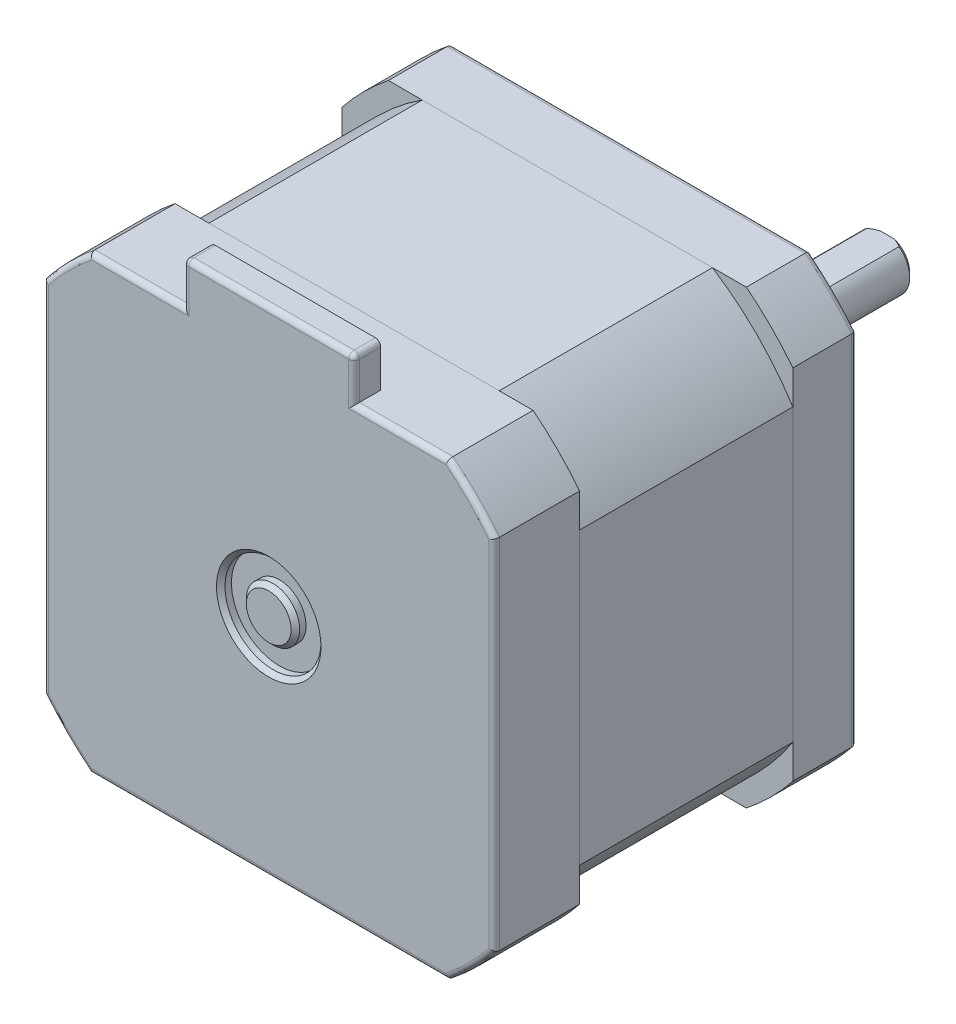
from build123d import *

# Parameters (mm, degrees)
BOSS_EXTRU_1_DEPTH           = 6
BOSS_EXTRU_2_DEPTH           = 20
BOSS_EXTRU_3_DEPTH           = 8
ESQUISSE4_W                  = 16
ESQUISSE4_H                  = 2.5
BOSS_EXTRU_4_DEPTH           = 4
ESQUISSE5_W                  = 2
ESQUISSE5_H                  = 6.5
ESQUISSE5_W_2                = 24
ESQUISSE5_H_2                = 2.5
CONG_1_R                     = 0.5
CONG_2_R                     = 0.5
CHANFREIN1_SIZE              = 0.4
CHANFREIN2_SIZE              = 0.4
ESQUISSE6_W                  = 15
ESQUISSE6_H                  = 0.5
ENL_V_MAT_EXTRU_1_DEPTH      = 22.1500001
ENL_V_MAT_EXTRU_1_DEPTH_BACK = 22.1500001
ESQUISSE7_R                  = 4.5
ESQUISSE7_R_2                = 2.5
ENL_V_MAT_EXTRU_2_DEPTH      = 1
CHANFREIN3_SIZE              = 0.4
TROU_TARAUD_M31_AT_2_COUNT   = 2
TROU_TARAUD_M31_AT_2_PITCH   = 31
TROU_TARAUD_M31_AT_3_COUNT   = 2
TROU_TARAUD_M31_AT_3_PITCH   = 43.840620434
TROU_TARAUD_M31_AT_4_COUNT   = 2
TROU_TARAUD_M31_AT_4_PITCH   = 31


with BuildPart() as part:
    # Esquisse1 → Boss.-Extru.1 (new body)
    with BuildSketch(Plane.XY):
        with BuildLine():
            Line((21.15, 16.783250579), (21.15, -16.783250579))
            ThreePointArc((21.15, -16.783250579), (19.091883092, -19.091883092), (16.783250579, -21.15))
            Line((16.783250579, -21.15), (-16.783250579, -21.15))
            ThreePointArc((-16.783250579, -21.15), (-19.091883092, -19.091883092), (-21.15, -16.783250579))
            Line((-21.15, -16.783250579), (-21.15, 16.783250579))
            ThreePointArc((-21.15, 16.783250579), (-19.091883092, 19.091883092), (-16.783250579, 21.15))
            Line((-16.783250579, 21.15), (16.783250579, 21.15))
            ThreePointArc((16.783250579, 21.15), (19.091883092, 19.091883092), (21.15, 16.783250579))
        make_face()
    extrude(amount=BOSS_EXTRU_1_DEPTH)

    # Congé2
    cong_2_edges = [part.edges().sort_by_distance(p)[0] for p in [
        (0, 21.15, 0),
        (19.091883092, 19.091883092, 0),
        (21.15, 0, 0),
        (19.091883092, -19.091883092, 0),
        (0, -21.15, 0),
        (-19.091883092, -19.091883092, 0),
        (-21.15, 0, 0),
        (-19.091883092, 19.091883092, 0),
    ]]
    fillet(cong_2_edges, radius=CONG_2_R)

    # Esquisse9 → Trou taraudé M31 (revolve, cut)
    with BuildSketch(Plane(origin=(15.5, -15.5, 0), x_dir=(0, 1, 0), z_dir=(1, 0, 0))):
        Polygon((0, 0), (0, 5.751075774), (1.25, 5), (1.25, 0), align=None)
    trou_taraud_m31 = revolve(axis=Axis((15.5, -15.5, -6.35), (0, 0, 1)), mode=Mode.SUBTRACT)

    # Trou taraudé M31 at 2: Trou taraudé M31 ×2
    with Locations(*[(0, i * TROU_TARAUD_M31_AT_2_PITCH, 0) for i in range(1, TROU_TARAUD_M31_AT_2_COUNT)]):
        add(trou_taraud_m31, mode=Mode.SUBTRACT)

    # Trou taraudé M31 at 3: Trou taraudé M31 ×2
    with Locations(*[Vector(-0.707106781, 0.707106781, 0) * (i * TROU_TARAUD_M31_AT_3_PITCH) for i in range(1, TROU_TARAUD_M31_AT_3_COUNT)]):
        add(trou_taraud_m31, mode=Mode.SUBTRACT)

    # Trou taraudé M31 at 4: Trou taraudé M31 ×2
    with Locations(*[(-i * TROU_TARAUD_M31_AT_4_PITCH, 0, 0) for i in range(1, TROU_TARAUD_M31_AT_4_COUNT)]):
        add(trou_taraud_m31, mode=Mode.SUBTRACT)


with BuildPart() as body_2:
    # Esquisse2 → Boss.-Extru.2 (new body)
    with BuildSketch(Plane.XY.offset(6)):
        with BuildLine():
            Line((-13.608820669, 21.15), (13.608820669, 21.15))
            ThreePointArc((13.608820669, 21.15), (17.783735547, 17.783735547), (21.15, 13.608820669))
            Line((21.15, 13.608820669), (21.15, -13.608820669))
            ThreePointArc((21.15, -13.608820669), (17.783735547, -17.783735547), (13.608820669, -21.15))
            Line((13.608820669, -21.15), (-13.608820669, -21.15))
            ThreePointArc((-13.608820669, -21.15), (-17.783735547, -17.783735547), (-21.15, -13.608820669))
            Line((-21.15, -13.608820669), (-21.15, 13.608820669))
            ThreePointArc((-21.15, 13.608820669), (-17.783735547, 17.783735547), (-13.608820669, 21.15))
        make_face()
    extrude(amount=BOSS_EXTRU_2_DEPTH)


with BuildPart() as body_3:
    # Esquisse3 → Boss.-Extru.3 (new body)
    with BuildSketch(Plane.XY.offset(26)):
        with BuildLine():
            Line((-16.783250579, -21.15), (16.783250579, -21.15))
            ThreePointArc((16.783250579, -21.15), (19.091883092, -19.091883092), (21.15, -16.783250579))
            Line((21.15, -16.783250579), (21.15, 16.783250579))
            ThreePointArc((21.15, 16.783250579), (19.091883092, 19.091883092), (16.783250579, 21.15))
            Line((16.783250579, 21.15), (-16.783250579, 21.15))
            ThreePointArc((-16.783250579, 21.15), (-19.091883092, 19.091883092), (-21.15, 16.783250579))
            Line((-21.15, 16.783250579), (-21.15, -16.783250579))
            ThreePointArc((-21.15, -16.783250579), (-19.091883092, -19.091883092), (-16.783250579, -21.15))
        make_face()
    extrude(amount=BOSS_EXTRU_3_DEPTH)

    # Esquisse4 → Boss.-Extru.4 (add)
    with BuildSketch(Plane(origin=(0, 21.15, 0), x_dir=(1, 0, 0), z_dir=(0, 1, 0))):
        with Locations((0, -32.75)):
            Rectangle(ESQUISSE4_W, ESQUISSE4_H)
    extrude(amount=BOSS_EXTRU_4_DEPTH)

    # Congé1
    cong_1_edges = [body_3.edges().sort_by_distance(p)[0] for p in [
        (19.091883092, -19.091883092, 34),
        (21.15, 0, 34),
        (19.091883092, 19.091883092, 34),
        (12.39162529, 21.15, 34),
        (-19.091883092, 19.091883092, 34),
        (-12.39162529, 21.15, 34),
        (-21.15, 0, 34),
        (8, 23.15, 34),
        (-8, 23.15, 34),
        (8, 25.15, 32.75),
        (-8, 25.15, 32.75),
        (0, 25.15, 34),
        (-19.091883092, -19.091883092, 34),
        (0, -21.15, 34),
    ]]
    fillet(cong_1_edges, radius=CONG_1_R)

    # Esquisse7 → Enlèv. mat.-Extru.2 (cut)
    with BuildSketch(Plane.XY.offset(34)):
        Circle(ESQUISSE7_R)
        Circle(ESQUISSE7_R_2, mode=Mode.SUBTRACT)
    extrude(amount=-ENL_V_MAT_EXTRU_2_DEPTH, mode=Mode.SUBTRACT)

    # Chanfrein3
    chanfrein3_edges = [body_3.edges().sort_by_distance(p)[0] for p in [
        (-4.5, 0, 34),
        (-2.5, 0, 34),
    ]]
    chamfer(chanfrein3_edges, length=CHANFREIN3_SIZE)


with BuildPart() as body_4:
    # Esquisse5 → Révolution1 (revolve)
    with BuildSketch(Plane(origin=(0, 0, 0), x_dir=(0, 0, -1), z_dir=(1, 0, 0))):
        with Locations((1, 7.75)):
            Rectangle(ESQUISSE5_W, ESQUISSE5_H)
        with Locations((12, 1.25)):
            Rectangle(ESQUISSE5_W_2, ESQUISSE5_H_2)
    revolve(axis=Axis((0, 0, 0), (0, 0, 1)))

    # Chanfrein1
    chanfrein1_edges = [body_4.edges().sort_by_distance(p)[0] for p in [
        (0, -2.5, -24),
    ]]
    chamfer(chanfrein1_edges, length=CHANFREIN1_SIZE)

    # Chanfrein2
    chanfrein2_edges = [body_4.edges().sort_by_distance(p)[0] for p in [
        (0, -11, -2),
        (0, -4.5, -2),
    ]]
    chamfer(chanfrein2_edges, length=CHANFREIN2_SIZE)

    # Esquisse6 → Enlèv. mat.-Extru.1 (cut, two sides)
    with BuildSketch(Plane(origin=(0, 0, 0), x_dir=(0, 0, -1), z_dir=(1, 0, 0))) as enl_v_mat_extru_1_sk:
        with Locations((16.5, 2.25)):
            Rectangle(ESQUISSE6_W, ESQUISSE6_H)
    extrude(amount=ENL_V_MAT_EXTRU_1_DEPTH, mode=Mode.SUBTRACT)
    extrude(enl_v_mat_extru_1_sk.sketch, amount=-ENL_V_MAT_EXTRU_1_DEPTH_BACK, mode=Mode.SUBTRACT)


solid = Compound([part.part, body_2.part, body_3.part, body_4.part])
